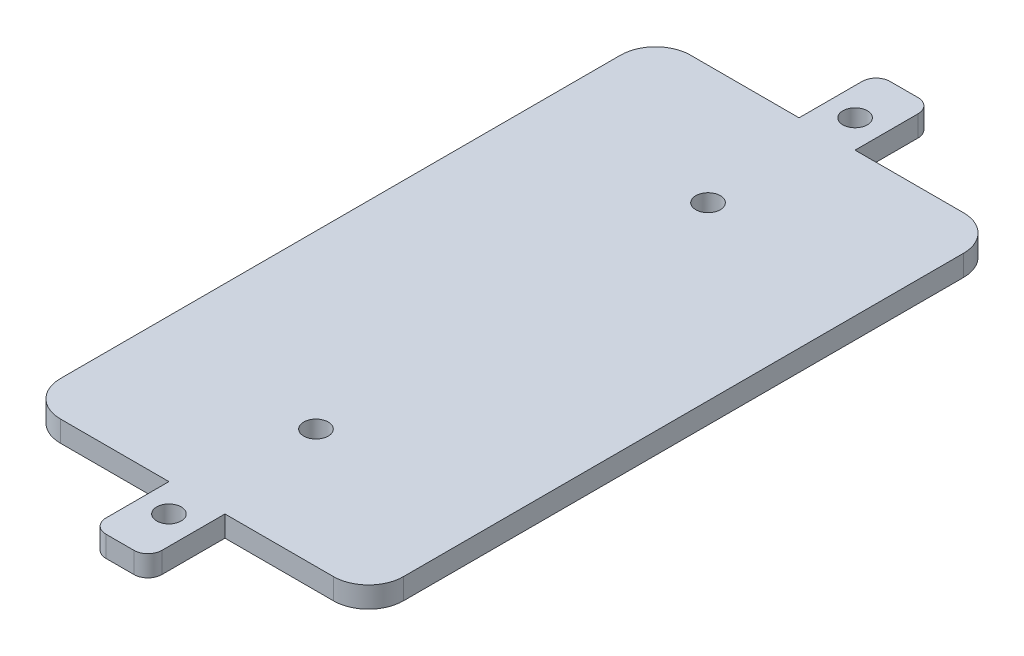
from build123d import *

# Parameters (mm, degrees)
SKETCH_1_W          = 49
SKETCH_1_H          = 90
SKETCH_1_R          = 1.75
EXTRUDE_1_DEPTH     = 3
FILLET_1_R          = 2
FILLET_2_R          = 5
CUT_EXTRUDE_1_DEPTH = 10


with BuildPart() as part:
    # 草图1 → 凸台-拉伸1 (new body)
    with BuildSketch(Plane(origin=(0, 0, 0), x_dir=(1, 0, 0), z_dir=(0, 1, 0))):
        Rectangle(SKETCH_1_W, SKETCH_1_H)
        Polygon((-4, 56), (-4, 45), (4, 45), (4, 56), (0, 56), align=None)
        with Locations((0, 49)):
            Circle(SKETCH_1_R, mode=Mode.SUBTRACT)
        Polygon((4, -45), (-4, -45), (-4, -56), (0, -56), (4, -56), align=None)
        with Locations((0, -49)):
            Circle(SKETCH_1_R, mode=Mode.SUBTRACT)
    extrude(amount=EXTRUDE_1_DEPTH)

    # 圆角1
    fillet_1_edges = [part.edges().sort_by_distance(p)[0] for p in [
        (-4, 1.5, -56),
        (4, 1.5, -56),
        (4, 1.5, 56),
        (-4, 1.5, 56),
    ]]
    fillet(fillet_1_edges, radius=FILLET_1_R)

    # 圆角2
    fillet_2_edges = [part.edges().sort_by_distance(p)[0] for p in [
        (-24.5, 1.5, 45),
        (-24.5, 1.5, -45),
        (24.5, 1.5, -45),
        (24.5, 1.5, 45),
    ]]
    fillet(fillet_2_edges, radius=FILLET_2_R)

    # 草图2 → 切除-拉伸1 (cut)
    with BuildSketch(Plane.XZ):
        with BuildLine():
            ThreePointArc((1.75, -28), (1.237436867, -26.762563133), (0, -26.25))
            Line((0, -26.25), (0, -28))
            Line((0, -28), (0, -29.75))
            ThreePointArc((0, -29.75), (1.237436867, -29.237436867), (1.75, -28))
        make_face()
        with BuildLine():
            Line((0, -28), (0, -26.25))
            ThreePointArc((0, -26.25), (-1.75, -28), (0, -29.75))
            Line((0, -29.75), (0, -28))
        make_face()
        with BuildLine():
            ThreePointArc((1.75, 28), (1.237436867, 29.237436867), (0, 29.75))
            Line((0, 29.75), (0, 28))
            Line((0, 28), (0, 26.25))
            ThreePointArc((0, 26.25), (1.237436867, 26.762563133), (1.75, 28))
        make_face()
        with BuildLine():
            Line((0, 28), (0, 29.75))
            ThreePointArc((0, 29.75), (-1.75, 28), (0, 26.25))
            Line((0, 26.25), (0, 28))
        make_face()
    extrude(amount=-CUT_EXTRUDE_1_DEPTH, mode=Mode.SUBTRACT)


solid = part.part
